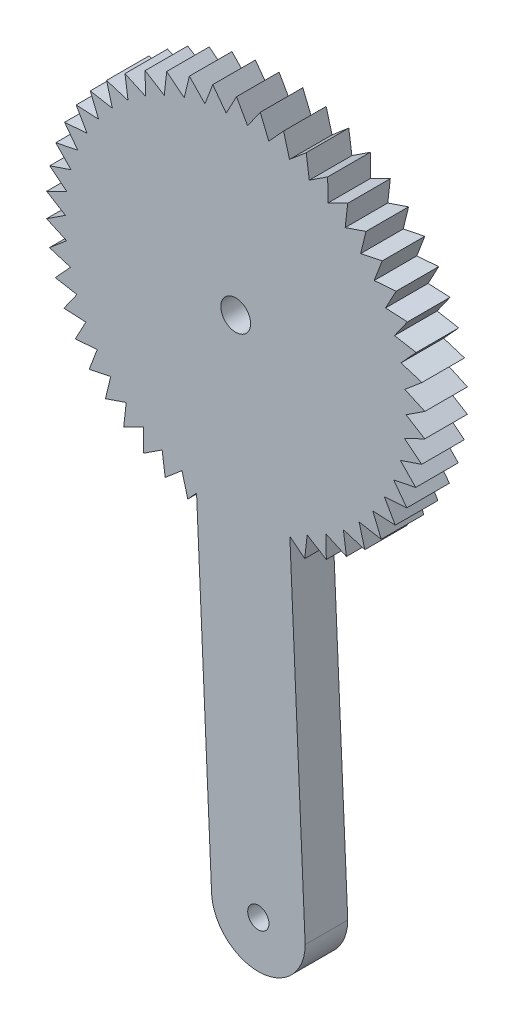
from build123d import *

# Parameters (mm, degrees)
SKETCH1_R           = 1.25
SKETCH1_R_2         = 1.75
BOSS_EXTRUDE2_DEPTH = 5


with BuildPart() as part:
    # Sketch1 → Boss-Extrude2 (new body)
    with BuildSketch(Plane.XY):
        with BuildLine():
            Line((349.257683179, 374.699911371), (348.046522548, 372.418831878))
            Line((348.046522548, 372.418831878), (346.468308818, 374.536137019))
            Line((346.468308818, 374.536137019), (345.55259362, 372.121245841))
            Line((345.55259362, 372.121245841), (343.721455877, 374.024052769))
            Line((343.721455877, 374.024052769), (343.115627486, 371.513434183))
            Line((343.115627486, 371.513434183), (341.060443866, 373.171734495))
            Line((341.060443866, 373.171734495), (340.774056559, 370.604982455))
            Line((340.774056559, 370.604982455), (338.527238535, 371.992623765))
            Line((338.527238535, 371.992623765), (338.564808811, 369.410217484))
            Line((338.564808811, 369.410217484), (336.161790046, 370.505315861))
            Line((336.161790046, 370.505315861), (336.522725398, 367.947981428))
            Line((336.522725398, 367.947981428), (334.001402933, 368.733266515))
            Line((334.001402933, 368.733266515), (334.680011196, 366.241334623))
            Line((334.680011196, 366.241334623), (332.080147792, 366.704422005))
            Line((332.080147792, 366.704422005), (333.065726908, 364.317191908))
            Line((333.065726908, 364.317191908), (330.428323965, 364.450778421))
            Line((330.428323965, 364.450778421), (331.705330762, 362.205898164))
            Line((331.705330762, 362.205898164), (329.0719817, 362.007877067))
            Line((329.0719817, 362.007877067), (330.620277019, 359.940749753))
            Line((330.620277019, 359.940749753), (328.032511325, 359.414243959))
            Line((328.032511325, 359.414243959), (329.827677623, 357.55746942))
            Line((329.827677623, 357.55746942), (327.326305908, 356.71078224))
            Line((327.326305908, 356.71078224), (329.34003234, 355.093642919))
            Line((329.34003234, 355.093642919), (326.964502731, 353.940127114))
            Line((326.964502731, 353.940127114), (329.165031629, 352.588126266))
            Line((329.165031629, 352.588126266), (326.952807646, 351.145973471))
            Line((326.952807646, 351.145973471), (329.305435355, 350.080432955))
            Line((329.305435355, 350.080432955), (327.291405091, 348.37238678))
            Line((327.291405091, 348.37238678), (329.759029266, 347.610110808))
            Line((329.759029266, 347.610110808), (327.974955183, 345.663108161))
            Line((327.974955183, 345.663108161), (330.518659917, 345.21611828))
            Line((330.518659917, 345.21611828), (328.992677928, 343.060864557))
            Line((328.992677928, 343.060864557), (331.572347478, 342.936210064))
            Line((331.572347478, 342.936210064), (330.328523231, 340.606694904))
            Line((330.328523231, 340.606694904), (332.903474666, 340.806341675))
            Line((332.903474666, 340.806341675), (331.961424013, 338.339302922))
            Line((331.961424013, 338.339302922), (334.491048812, 338.860102409))
            Line((334.491048812, 338.860102409), (333.865628454, 336.294446739))
            Line((333.865628454, 336.294446739), (336.310032922, 337.128185622))
            Line((336.310032922, 337.128185622), (336.011106111, 334.504374958))
            Line((336.011106111, 334.504374958), (338.331740529, 335.637904676))
            Line((338.331740529, 335.637904676), (338.364021521, 332.997318079))
            Line((338.364021521, 332.997318079), (340.524288099, 334.412762192))
            Line((340.524288099, 334.412762192), (340.887267801, 331.797043291))
            Line((340.887267801, 331.797043291), (342.853097845, 333.4720794))
            Line((342.853097845, 333.4720794), (343.541051852, 330.922479643))
            Line((343.541051852, 330.922479643), (344.568787794, 332.049317014))
            Line((344.568787794, 332.049317014), (346.321351139, 292.508956491))
            ThreePointArc((346.321351139, 292.508956491), (351.821351139, 287.008956491), (357.321351139, 292.508956491))
            Line((357.321351139, 292.508956491), (357.299783306, 292.995557967))
            Line((357.299783306, 292.995557967), (355.520486612, 333.139061449))
            Line((355.520486612, 333.139061449), (357.268666905, 331.728478036))
            Line((357.268666905, 331.728478036), (357.555054212, 334.295230076))
            Line((357.555054212, 334.295230076), (359.801872235, 332.907588766))
            Line((359.801872235, 332.907588766), (359.76430196, 335.489995047))
            Line((359.76430196, 335.489995047), (362.167320725, 334.394896671))
            Line((362.167320725, 334.394896671), (361.806385373, 336.952231103))
            Line((361.806385373, 336.952231103), (364.327707838, 336.166946016))
            Line((364.327707838, 336.166946016), (363.649099575, 338.658877908))
            Line((363.649099575, 338.658877908), (366.248962979, 338.195790526))
            Line((366.248962979, 338.195790526), (365.263383863, 340.583020623))
            Line((365.263383863, 340.583020623), (367.900786806, 340.449434111))
            Line((367.900786806, 340.449434111), (366.623780008, 342.694314367))
            Line((366.623780008, 342.694314367), (369.257129071, 342.892335464))
            Line((369.257129071, 342.892335464), (367.708833752, 344.959462778))
            Line((367.708833752, 344.959462778), (370.296599446, 345.485968572))
            Line((370.296599446, 345.485968572), (368.501433148, 347.342743111))
            Line((368.501433148, 347.342743111), (371.002804863, 348.189430292))
            Line((371.002804863, 348.189430292), (368.98907843, 349.806569612))
            Line((368.98907843, 349.806569612), (371.36460804, 350.960085417))
            Line((371.36460804, 350.960085417), (369.164079142, 352.312086265))
            Line((369.164079142, 352.312086265), (371.376303125, 353.754239061))
            Line((371.376303125, 353.754239061), (369.023675416, 354.819779576))
            Line((369.023675416, 354.819779576), (371.03770568, 356.527825751))
            Line((371.03770568, 356.527825751), (368.570081505, 357.290101724))
            Line((368.570081505, 357.290101724), (370.354155588, 359.23710437))
            Line((370.354155588, 359.23710437), (367.810450854, 359.684094251))
            Line((367.810450854, 359.684094251), (369.336432842, 361.839347974))
            Line((369.336432842, 361.839347974), (366.756763293, 361.964002467))
            Line((366.756763293, 361.964002467), (368.00058754, 364.293517627))
            Line((368.00058754, 364.293517627), (365.425636104, 364.093870857))
            Line((365.425636104, 364.093870857), (366.367686758, 366.560909609))
            Line((366.367686758, 366.560909609), (363.838061959, 366.040110123))
            Line((363.838061959, 366.040110123), (364.463482317, 368.605765792))
            Line((364.463482317, 368.605765792), (362.019077849, 367.77202691))
            Line((362.019077849, 367.77202691), (362.31800466, 370.395837574))
            Line((362.31800466, 370.395837574), (359.997370241, 369.262307855))
            Line((359.997370241, 369.262307855), (359.96508925, 371.902894452))
            Line((359.96508925, 371.902894452), (357.804822672, 370.487450339))
            Line((357.804822672, 370.487450339), (357.441842969, 373.103169241))
            Line((357.441842969, 373.103169241), (355.476012926, 371.428133131))
            Line((355.476012926, 371.428133131), (354.788058919, 373.977732888))
            Line((354.788058919, 373.977732888), (353.047667725, 372.069521103))
            Line((353.047667725, 372.069521103), (352.045588858, 374.512793004))
            Line((352.045588858, 374.512793004), (350.558083522, 372.401499183))
            Line((350.558083522, 372.401499183), (349.257683179, 374.699911371))
        make_face()
        with Locations((351.821351139, 292.508956491)):
            Circle(SKETCH1_R, mode=Mode.SUBTRACT)
        with Locations((349.164555385, 352.450106266)):
            Circle(SKETCH1_R_2, mode=Mode.SUBTRACT)
    extrude(amount=BOSS_EXTRUDE2_DEPTH)


solid = part.part
